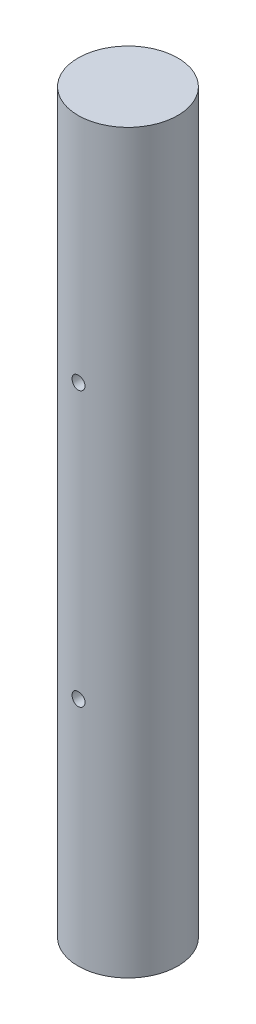
from build123d import *

# Parameters (mm, degrees)
SKETCH2_R           = 11.5
BOSS_EXTRUDE1_DEPTH = 170
CUT_EXTRUDE1_REACH  = 13.5
SKETCH3_R           = 1.5


with BuildPart() as part:
    # Sketch2 → Boss-Extrude1 (new body)
    with BuildSketch(Plane(origin=(0, 0, 0), x_dir=(1, 0, 0), z_dir=(0, 1, 0))):
        Circle(SKETCH2_R)
    extrude(amount=BOSS_EXTRUDE1_DEPTH)

    # Sketch3 → Cut-Extrude1 (cut, up to next)
    with BuildSketch(Plane.XY, mode=Mode.PRIVATE) as cut_extrude1_sk1:
        with Locations((0, 53.38)):
            Circle(SKETCH3_R)
    cut_extrude1_tool1 = extrude(cut_extrude1_sk1.sketch, amount=CUT_EXTRUDE1_REACH, mode=Mode.PRIVATE) & part.part
    add(cut_extrude1_tool1.solids().sort_by_distance((0, 53.38, 0))[0], mode=Mode.SUBTRACT)
    # Sketch3 → Cut-Extrude1 (cut, up to next)
    with BuildSketch(Plane.XY, mode=Mode.PRIVATE) as cut_extrude1_sk2:
        with Locations((0, 116.62)):
            Circle(SKETCH3_R)
    cut_extrude1_tool2 = extrude(cut_extrude1_sk2.sketch, amount=CUT_EXTRUDE1_REACH, mode=Mode.PRIVATE) & part.part
    add(cut_extrude1_tool2.solids().sort_by_distance((0, 116.62, 0))[0], mode=Mode.SUBTRACT)


solid = part.part
